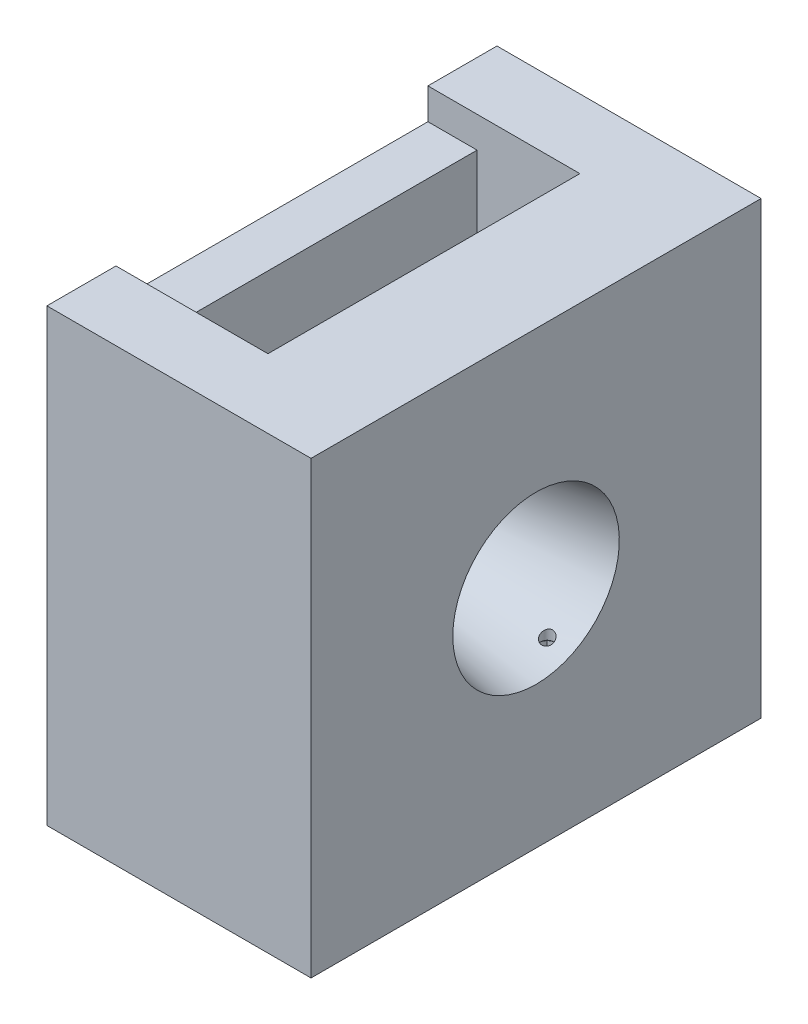
from build123d import *

# Parameters (mm, degrees)
ESBO_O1_W                     = 29000
ESBO_O1_H                     = 29000
RESSALTO_EXTRUS_O1_DEPTH      = 10050
RESSALTO_EXTRUS_O1_DEPTH_BACK = 6970
CORTE_EXTRUS_O1_DEPTH         = 10050
CORTE_EXTRUS_O1_DEPTH_BACK    = 10050
ESBO_O4_W                     = 1600
ESBO_O4_H                     = 1600
CORTE_EXTRUS_O2_DEPTH         = 6050
CORTE_EXTRUS_O3_REACH         = 19616
ESBO_O5_R                     = 400
ESBO_O8_R                     = 495
CORTE_EXTRUS_O4_DEPTH         = 90


with BuildPart() as part:
    # Esboço1 → Ressalto-extrusão1 (new body, two sides)
    with BuildSketch(Plane(origin=(0, 0, 0), x_dir=(0, 0, -1), z_dir=(1, 0, 0))) as ressalto_extrus_o1_sk:
        Rectangle(ESBO_O1_W, ESBO_O1_H)
    extrude(amount=RESSALTO_EXTRUS_O1_DEPTH)
    extrude(ressalto_extrus_o1_sk.sketch, amount=-RESSALTO_EXTRUS_O1_DEPTH_BACK)

    # Esboço2 → Corte-Revolução1 (revolve, cut)
    with BuildSketch(Plane.XY):
        Polygon((2824, 4113), (10050, 5365), (10050, 0), (2824, 0), align=None)
        Polygon((-3800, 5521.5), (-6970, 7639), (-6970, 0), (-3800, 0), align=None)
    revolve(axis=Axis((0, 0, 0), (1, 0, 0)), mode=Mode.SUBTRACT)

    # Esboço3 → Corte-extrusão1 (cut, two sides)
    with BuildSketch(Plane.XY) as corte_extrus_o1_sk:
        Polygon((-3800, -9164), (-3800, 12500), (-6970, 12500), (-6970, 14500), (2824, 14500), (2824, -9164), (9370, -9164), (9370, -11164), (-6970, -11164), (-6970, -9164), align=None)
    extrude(amount=CORTE_EXTRUS_O1_DEPTH, mode=Mode.SUBTRACT)
    extrude(corte_extrus_o1_sk.sketch, amount=-CORTE_EXTRUS_O1_DEPTH_BACK, mode=Mode.SUBTRACT)

    # Esboço4 → Corte-extrusão2 (cut)
    with BuildSketch(Plane(origin=(0, -11164, 0), x_dir=(1, 0, 0), z_dir=(0, 1, 0))):
        with Locations((8570, 2200)):
            Rectangle(ESBO_O4_W, ESBO_O4_H)
    extrude(amount=CORTE_EXTRUS_O2_DEPTH, mode=Mode.SUBTRACT)

    # Esboço5 → Corte-extrusão3 (cut, up to next)
    with BuildSketch(Plane(origin=(0, -5114, 0), x_dir=(-1, 0, 0), z_dir=(0, -1, 0)), mode=Mode.PRIVATE) as corte_extrus_o3_sk1:
        with Locations((-8570, 2200)):
            Circle(ESBO_O5_R)
    corte_extrus_o3_tool1 = extrude(corte_extrus_o3_sk1.sketch, amount=-CORTE_EXTRUS_O3_REACH, mode=Mode.PRIVATE) & part.part
    add(corte_extrus_o3_tool1.solids().sort_by_distance((8570, -5114, -2200))[0], mode=Mode.SUBTRACT)

    # Esboço8 → Corte-extrusão4 (cut)
    with BuildSketch(Plane.XZ.offset(5114)):
        with Locations((8570, -2200)):
            Circle(ESBO_O8_R)
    extrude(amount=-CORTE_EXTRUS_O4_DEPTH, mode=Mode.SUBTRACT)


solid = part.part
